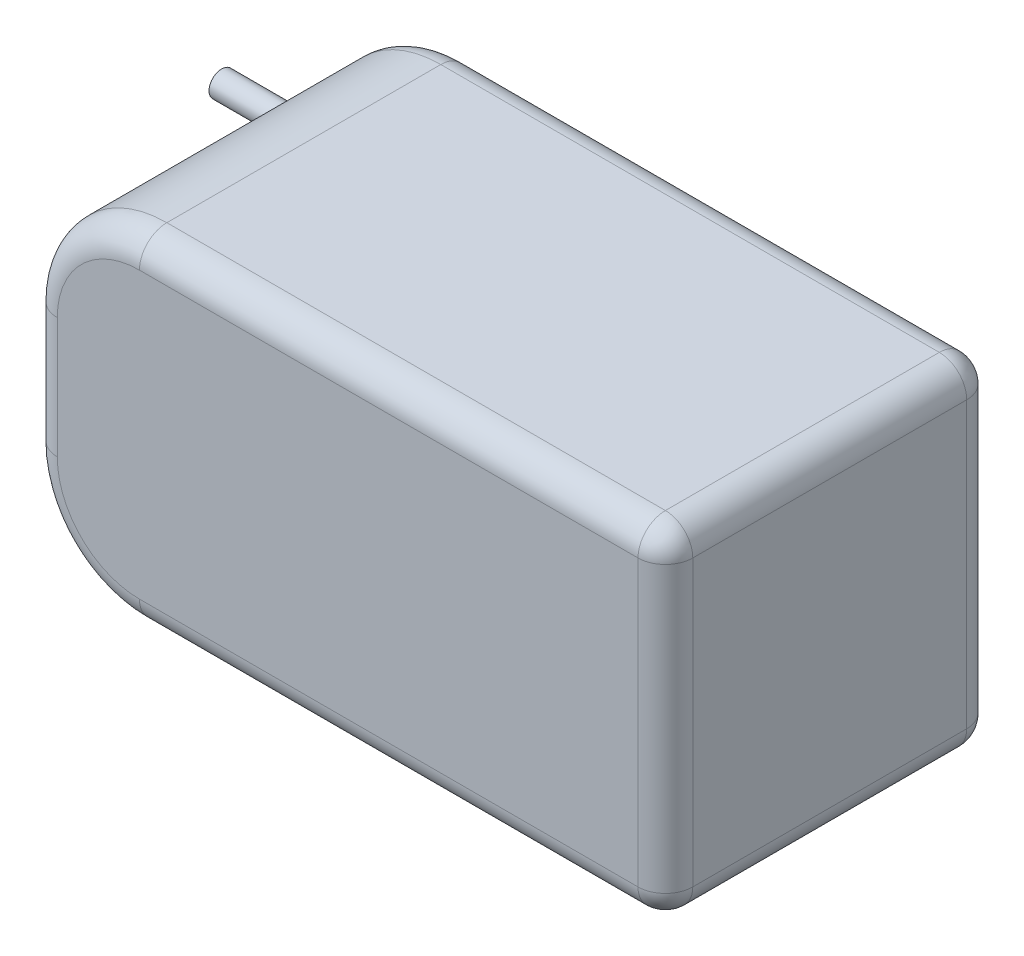
from build123d import *

# Parameters (mm, degrees)
SKETCH1_W           = 58
SKETCH1_H           = 30
BOSS_EXTRUDE1_DEPTH = 31
FILLET1_R           = 10
FILLET2_R           = 2.5
SKETCH2_R           = 1.15
BOSS_EXTRUDE2_DEPTH = 10


with BuildPart() as part:
    # Sketch1 → Boss-Extrude1 (new body)
    with BuildSketch(Plane(origin=(0, 0, 0), x_dir=(1, 0, 0), z_dir=(0, 1, 0))):
        Rectangle(SKETCH1_W, SKETCH1_H)
    extrude(amount=BOSS_EXTRUDE1_DEPTH)

    # Fillet1
    fillet1_edges = [part.edges().sort_by_distance(p)[0] for p in [
        (-29, 31, 0),
        (-29, 0, 0),
    ]]
    fillet(fillet1_edges, radius=FILLET1_R)

    # Fillet2
    fillet2_edges = [part.edges().sort_by_distance(p)[0] for p in [
        (-29, 15.5, 15),
        (-29, 15.5, -15),
        (5, 0, 15),
        (5, 31, 15),
        (-26.071067812, 28.071067812, 15),
        (-26.071067812, 2.928932188, 15),
        (-26.071067812, 28.071067812, -15),
        (-26.071067812, 2.928932188, -15),
        (29, 31, 0),
        (5, 0, -15),
        (29, 0, 0),
        (5, 31, -15),
        (29, 15.5, 15),
        (29, 15.5, -15),
    ]]
    fillet(fillet2_edges, radius=FILLET2_R)

    # Sketch2 → Boss-Extrude2 (add)
    with BuildSketch(Plane.ZY.offset(29)):
        with Locations((-12.5, 19.5)):
            Circle(SKETCH2_R)
        with Locations((-12.5, 11.5)):
            Circle(SKETCH2_R)
    extrude(amount=BOSS_EXTRUDE2_DEPTH)


solid = part.part
